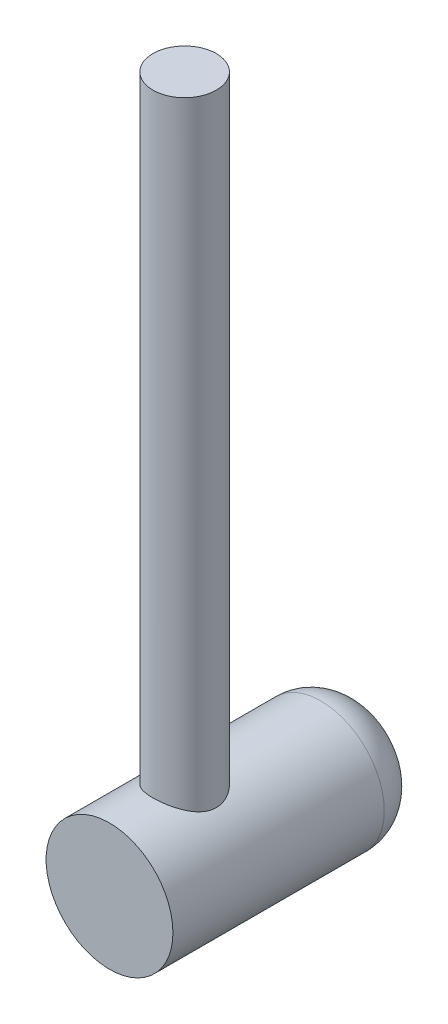
from build123d import *

# Parameters (mm, degrees)
SKETCH1_R           = 750
BOSS_EXTRUDE1_DEPTH = 3000
FILLET1_R           = 500
SKETCH2_R           = 375
BOSS_EXTRUDE2_DEPTH = 8000


with BuildPart() as part:
    # Sketch1 → Boss-Extrude1 (new body)
    with BuildSketch(Plane.XY):
        Circle(SKETCH1_R)
    extrude(amount=BOSS_EXTRUDE1_DEPTH)

    # Fillet1
    fillet1_edges = [part.edges().sort_by_distance(p)[0] for p in [
        (-750, 0, 0),
    ]]
    fillet(fillet1_edges, radius=FILLET1_R)

    # Sketch2 → Boss-Extrude2 (add)
    with BuildSketch(Plane(origin=(0, 0, 0), x_dir=(1, 0, 0), z_dir=(0, 1, 0))):
        with Locations((0, -2111.63545154)):
            Circle(SKETCH2_R)
    extrude(amount=BOSS_EXTRUDE2_DEPTH)


solid = part.part
